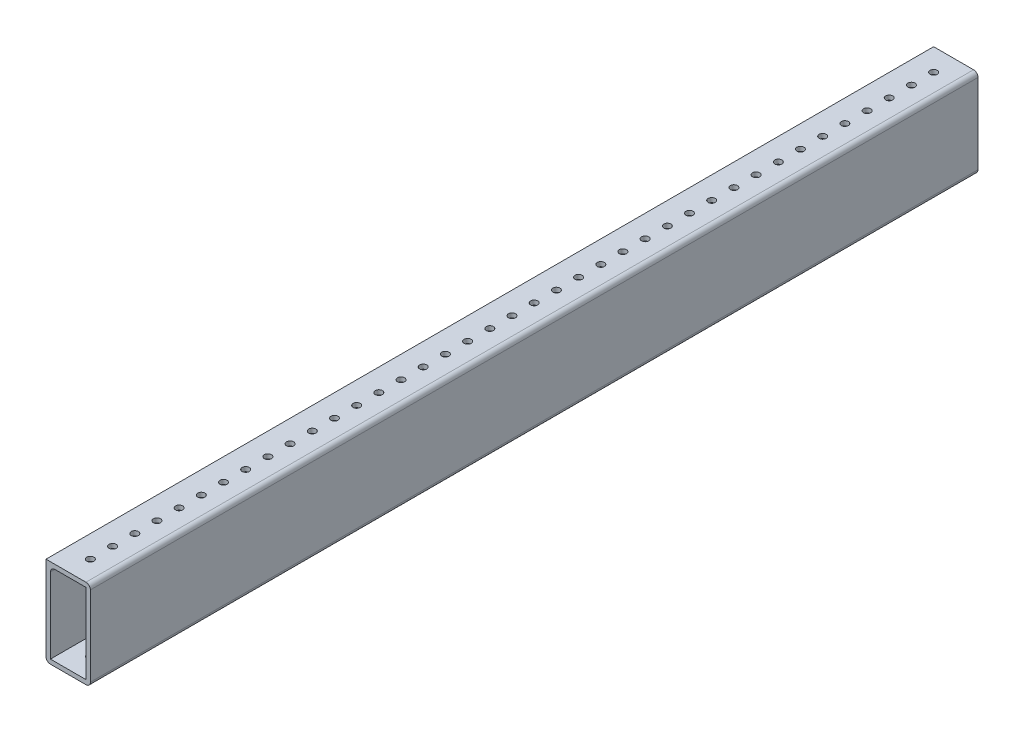
from build123d import *

# Parameters (mm, degrees)
SKETCH1_W           = 25.4
SKETCH1_H           = 50.8
SKETCH1_W_2         = 20.32
SKETCH1_H_2         = 45.72
BOSS_EXTRUDE1_DEPTH = 508
SKETCH2_R           = 2.032
CUT_EXTRUDE1_DEPTH  = 508
FILLET1_R           = 2.54


with BuildPart() as part:
    # Sketch1 → Boss-Extrude1 (new body)
    with BuildSketch(Plane.XY):
        with Locations((12.7, 25.4)):
            Rectangle(SKETCH1_W, SKETCH1_H)
        with Locations((12.7, 25.4)):
            Rectangle(SKETCH1_W_2, SKETCH1_H_2, mode=Mode.SUBTRACT)
    extrude(amount=BOSS_EXTRUDE1_DEPTH)

    # Sketch2 → Cut-Extrude1 (cut)
    with BuildSketch(Plane(origin=(0, 50.8, 0), x_dir=(1, 0, 0), z_dir=(0, 1, 0))):
        with Locations((12.7, -12.7)):
            Circle(SKETCH2_R)
        with Locations((12.7, -25.4)):
            Circle(SKETCH2_R)
        with Locations((12.7, -38.1)):
            Circle(SKETCH2_R)
        with Locations((12.7, -50.8)):
            Circle(SKETCH2_R)
        with Locations((12.7, -63.5)):
            Circle(SKETCH2_R)
        with Locations((12.7, -76.2)):
            Circle(SKETCH2_R)
        with Locations((12.7, -88.9)):
            Circle(SKETCH2_R)
        with Locations((12.7, -101.6)):
            Circle(SKETCH2_R)
        with Locations((12.7, -114.3)):
            Circle(SKETCH2_R)
        with Locations((12.7, -127)):
            Circle(SKETCH2_R)
        with Locations((12.7, -139.7)):
            Circle(SKETCH2_R)
        with Locations((12.7, -152.4)):
            Circle(SKETCH2_R)
        with Locations((12.7, -165.1)):
            Circle(SKETCH2_R)
        with Locations((12.7, -177.8)):
            Circle(SKETCH2_R)
        with Locations((12.7, -190.5)):
            Circle(SKETCH2_R)
        with Locations((12.7, -203.2)):
            Circle(SKETCH2_R)
        with Locations((12.7, -215.9)):
            Circle(SKETCH2_R)
        with Locations((12.7, -228.6)):
            Circle(SKETCH2_R)
        with Locations((12.7, -241.3)):
            Circle(SKETCH2_R)
        with Locations((12.7, -254)):
            Circle(SKETCH2_R)
        with Locations((12.7, -266.7)):
            Circle(SKETCH2_R)
        with Locations((12.7, -279.4)):
            Circle(SKETCH2_R)
        with Locations((12.7, -292.1)):
            Circle(SKETCH2_R)
        with Locations((12.7, -304.8)):
            Circle(SKETCH2_R)
        with Locations((12.7, -317.5)):
            Circle(SKETCH2_R)
        with Locations((12.7, -330.2)):
            Circle(SKETCH2_R)
        with Locations((12.7, -342.9)):
            Circle(SKETCH2_R)
        with Locations((12.7, -355.6)):
            Circle(SKETCH2_R)
        with Locations((12.7, -368.3)):
            Circle(SKETCH2_R)
        with Locations((12.7, -381)):
            Circle(SKETCH2_R)
        with Locations((12.7, -393.7)):
            Circle(SKETCH2_R)
        with Locations((12.7, -406.4)):
            Circle(SKETCH2_R)
        with Locations((12.7, -419.1)):
            Circle(SKETCH2_R)
        with Locations((12.7, -431.8)):
            Circle(SKETCH2_R)
        with Locations((12.7, -444.5)):
            Circle(SKETCH2_R)
        with Locations((12.7, -457.2)):
            Circle(SKETCH2_R)
        with Locations((12.7, -469.9)):
            Circle(SKETCH2_R)
        with Locations((12.7, -482.6)):
            Circle(SKETCH2_R)
        with Locations((12.7, -495.3)):
            Circle(SKETCH2_R)
    extrude(amount=-CUT_EXTRUDE1_DEPTH, mode=Mode.SUBTRACT)

    # Fillet1
    fillet1_edges = [part.edges().sort_by_distance(p)[0] for p in [
        (2.54, 48.26, 254),
        (25.4, 50.8, 254),
        (25.4, 0, 254),
        (0, 0, 254),
    ]]
    fillet(fillet1_edges, radius=FILLET1_R)


solid = part.part
